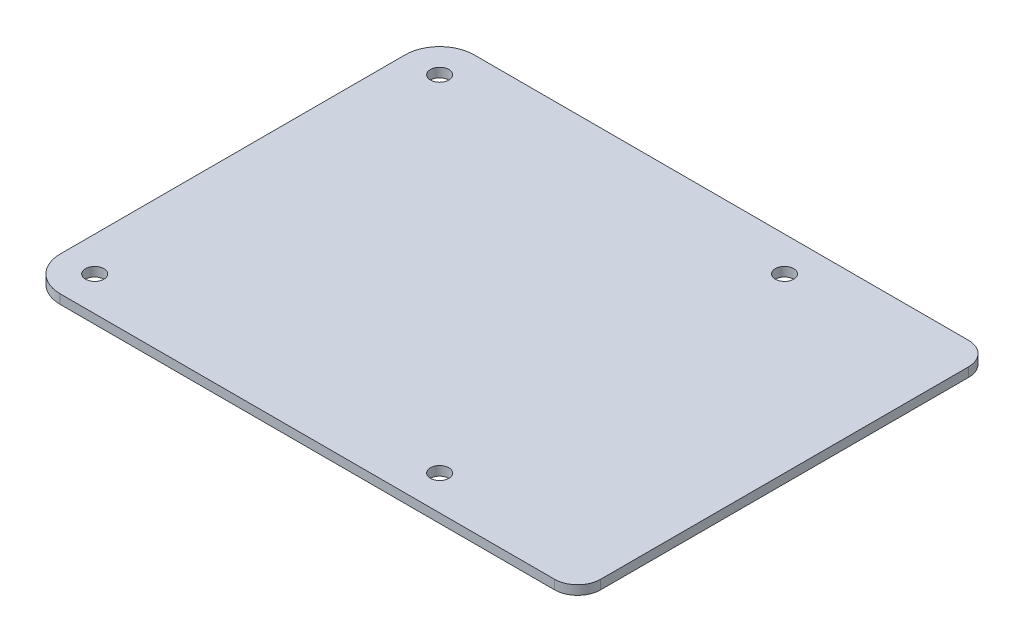
from build123d import *

# Parameters (mm, degrees)
SKETCH1_R           = 1.6
BOSS_EXTRUDE1_DEPTH = 1.6
FILLET1_R           = 4


with BuildPart() as part:
    # Sketch1 → Boss-Extrude1 (new body)
    with BuildSketch(Plane(origin=(0, 0, 0), x_dir=(1, 0, 0), z_dir=(0, 1, 0))):
        with BuildLine():
            Line((-34, 30), (-34, -30))
            ThreePointArc((-34, -30), (-32.242640687, -34.242640687), (-28, -36))
            Line((-28, -36), (62, -36))
            Line((62, -36), (62, 36))
            Line((62, 36), (-28, 36))
            ThreePointArc((-28, 36), (-32.242640687, 34.242640687), (-34, 30))
        make_face()
        with Locations((-28, 30)):
            Circle(SKETCH1_R, mode=Mode.SUBTRACT)
        with Locations((32, 30)):
            Circle(SKETCH1_R, mode=Mode.SUBTRACT)
        with Locations((32, -30)):
            Circle(SKETCH1_R, mode=Mode.SUBTRACT)
        with Locations((-28, -30)):
            Circle(SKETCH1_R, mode=Mode.SUBTRACT)
    extrude(amount=BOSS_EXTRUDE1_DEPTH)

    # Fillet1
    fillet1_edges = [part.edges().sort_by_distance(p)[0] for p in [
        (62, 0.8, -36),
        (62, 0.8, 36),
    ]]
    fillet(fillet1_edges, radius=FILLET1_R)


solid = part.part
